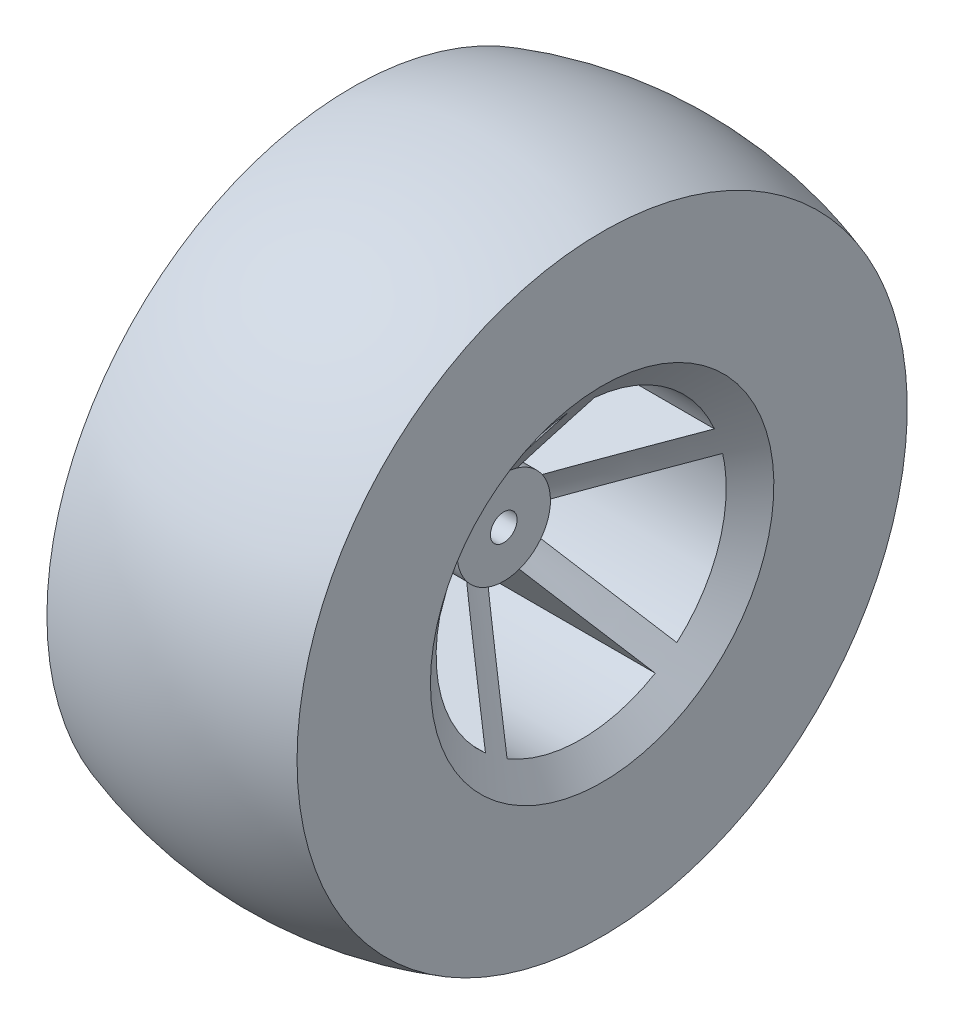
from build123d import *

# Parameters (mm, degrees)
CUT_EXTRUDE1_DEPTH      = 19.7500001
CUT_EXTRUDE1_DEPTH_BACK = 19.7500001


with BuildPart() as part:
    # Sketch1 → Revolve1 (revolve)
    with BuildSketch(Plane(origin=(0, 0, 0), x_dir=(1, 0, 0), z_dir=(0, 1, 0))):
        with BuildLine():
            Line((18.75, -45.745065576), (18.75, -25.745065576))
            Line((18.75, -25.745065576), (4, -7))
            Line((4, -7), (4, -2))
            Line((4, -2), (0, -2))
            Line((0, -2), (0, -48.75))
            ThreePointArc((0, -48.75), (9.494631785, -47.99400364), (18.75, -45.745065576))
        make_face()
    revolve(axis=Axis((-21.521301372, 0, 0), (1, 0, 0)))

    # Mirror1: part across plane


with BuildPart() as part_1:
    add(part.part)
    add(part.part.mirror(Plane(origin=(0, 0, 2), x_dir=(0, 0, 1), z_dir=(-1, 0, 0))))

    # Sketch2 → Cut-Extrude1 (cut, two sides)
    with BuildSketch(Plane(origin=(0, 0, 0), x_dir=(0, 0, -1), z_dir=(1, 0, 0))) as cut_extrude1_sk:
        with BuildLine():
            ThreePointArc((-5.761847074, 3.975062049), (-4.114496766, 5.663118961), (-2, 6.708203932))
            Line((-2, 6.708203932), (-2, 21.652895347))
            ThreePointArc((-2, 21.652895347), (-12.781428856, 17.592127595), (-19.975093227, 8.593225672))
            Line((-19.975093227, 8.593225672), (-5.761847074, 3.975062049))
        make_face()
        with BuildLine():
            Line((2, 21.652895347), (2, 6.708203932))
            ThreePointArc((2, 6.708203932), (4.114496766, 5.663118961), (5.761847074, 3.975062049))
            Line((5.761847074, 3.975062049), (19.975093227, 8.593225672))
            ThreePointArc((19.975093227, 8.593225672), (12.781428856, 17.592127595), (2, 21.652895347))
        make_face()
        with BuildLine():
            Line((-14.345286543, -16.341989808), (-5.56101733, -4.251480479))
            ThreePointArc((-5.56101733, -4.251480479), (-6.657395614, -2.163118961), (-6.997915051, 0.170835984))
            Line((-6.997915051, 0.170835984), (-21.211161205, 4.788999607))
            ThreePointArc((-21.211161205, 4.788999607), (-20.680786313, -6.719594807), (-14.345286543, -16.341989808))
        make_face()
        with BuildLine():
            Line((21.211161205, 4.788999607), (6.997915051, 0.170835984))
            ThreePointArc((6.997915051, 0.170835984), (6.999478743, 0.085424353), (7, 0))
            ThreePointArc((7, 0), (6.630502293, -2.244201271), (5.56101733, -4.251480479))
            Line((5.56101733, -4.251480479), (14.345286543, -16.341989808))
            ThreePointArc((14.345286543, -16.341989808), (19.808925684, -8.969634338), (21.745065576, 0))
            ThreePointArc((21.745065576, 0), (21.611177296, 2.409334509), (21.211161205, 4.788999607))
        make_face()
        with BuildLine():
            Line((11.109218566, -18.693130818), (2.324949352, -6.602621488))
            ThreePointArc((2.324949352, -6.602621488), (0, -7), (-2.324949352, -6.602621488))
            Line((-2.324949352, -6.602621488), (-11.109218566, -18.693130818))
            ThreePointArc((-11.109218566, -18.693130818), (0, -21.745065576), (11.109218566, -18.693130818))
        make_face()
    extrude(amount=CUT_EXTRUDE1_DEPTH, mode=Mode.SUBTRACT)
    extrude(cut_extrude1_sk.sketch, amount=-CUT_EXTRUDE1_DEPTH_BACK, mode=Mode.SUBTRACT)


solid = part_1.part
